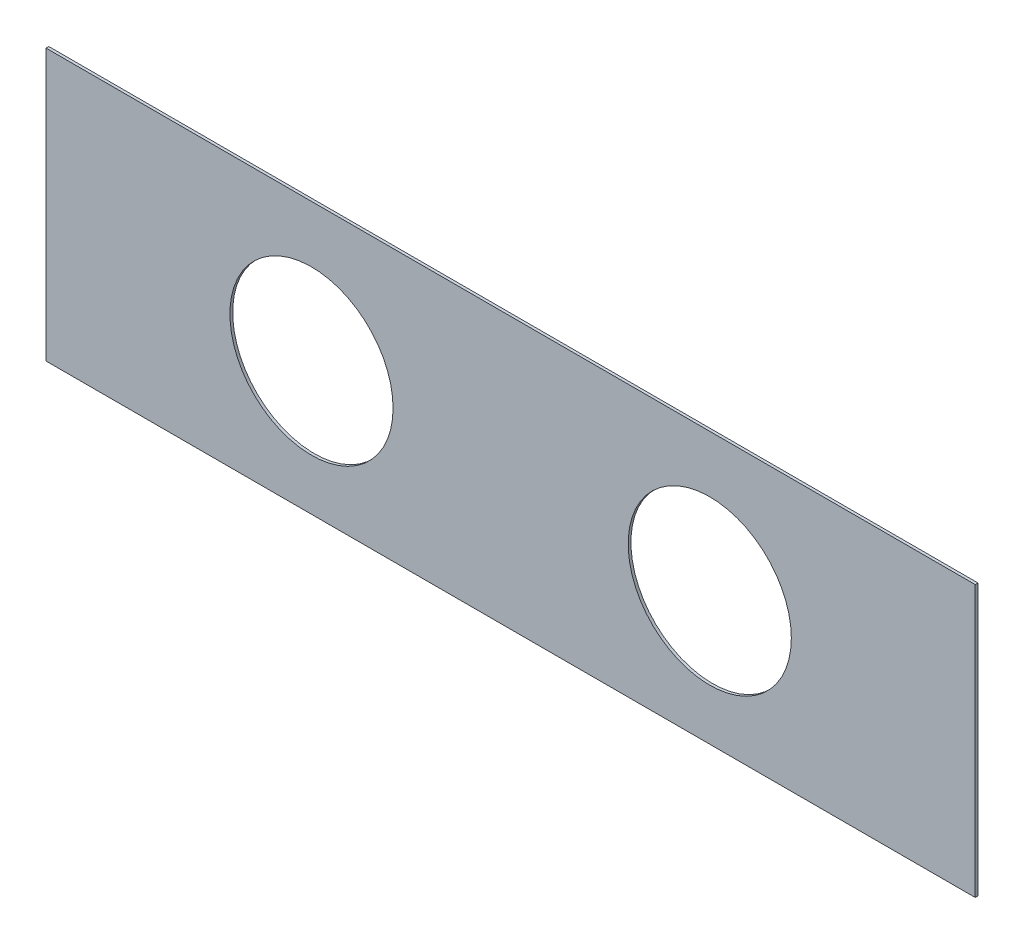
from build123d import *

# Parameters (mm, degrees)
SKETCH1_W           = 1066.8
SKETCH1_H           = 311.15
BOSS_EXTRUDE1_DEPTH = 3.175
CUT_EXTRUDE1_REACH  = 5.175
SKETCH2_R           = 93.6625


with BuildPart() as part:
    # Sketch1 → Boss-Extrude1 (new body)
    with BuildSketch(Plane.XY):
        Rectangle(SKETCH1_W, SKETCH1_H)
    extrude(amount=BOSS_EXTRUDE1_DEPTH)

    # Sketch2 → Cut-Extrude1 (cut, up to next)
    with BuildSketch(Plane.XY.offset(3.175), mode=Mode.PRIVATE) as cut_extrude1_sk1:
        with Locations((228.6, -3.175)):
            Circle(SKETCH2_R)
    cut_extrude1_tool1 = extrude(cut_extrude1_sk1.sketch, amount=-CUT_EXTRUDE1_REACH, mode=Mode.PRIVATE) & part.part
    add(cut_extrude1_tool1.solids().sort_by_distance((228.6, -3.175, 3.175))[0], mode=Mode.SUBTRACT)
    # Sketch2 → Cut-Extrude1 (cut, up to next)
    with BuildSketch(Plane.XY.offset(3.175), mode=Mode.PRIVATE) as cut_extrude1_sk2:
        with Locations((-228.6, -3.175)):
            Circle(SKETCH2_R)
    cut_extrude1_tool2 = extrude(cut_extrude1_sk2.sketch, amount=-CUT_EXTRUDE1_REACH, mode=Mode.PRIVATE) & part.part
    add(cut_extrude1_tool2.solids().sort_by_distance((-228.6, -3.175, 3.175))[0], mode=Mode.SUBTRACT)


solid = part.part
